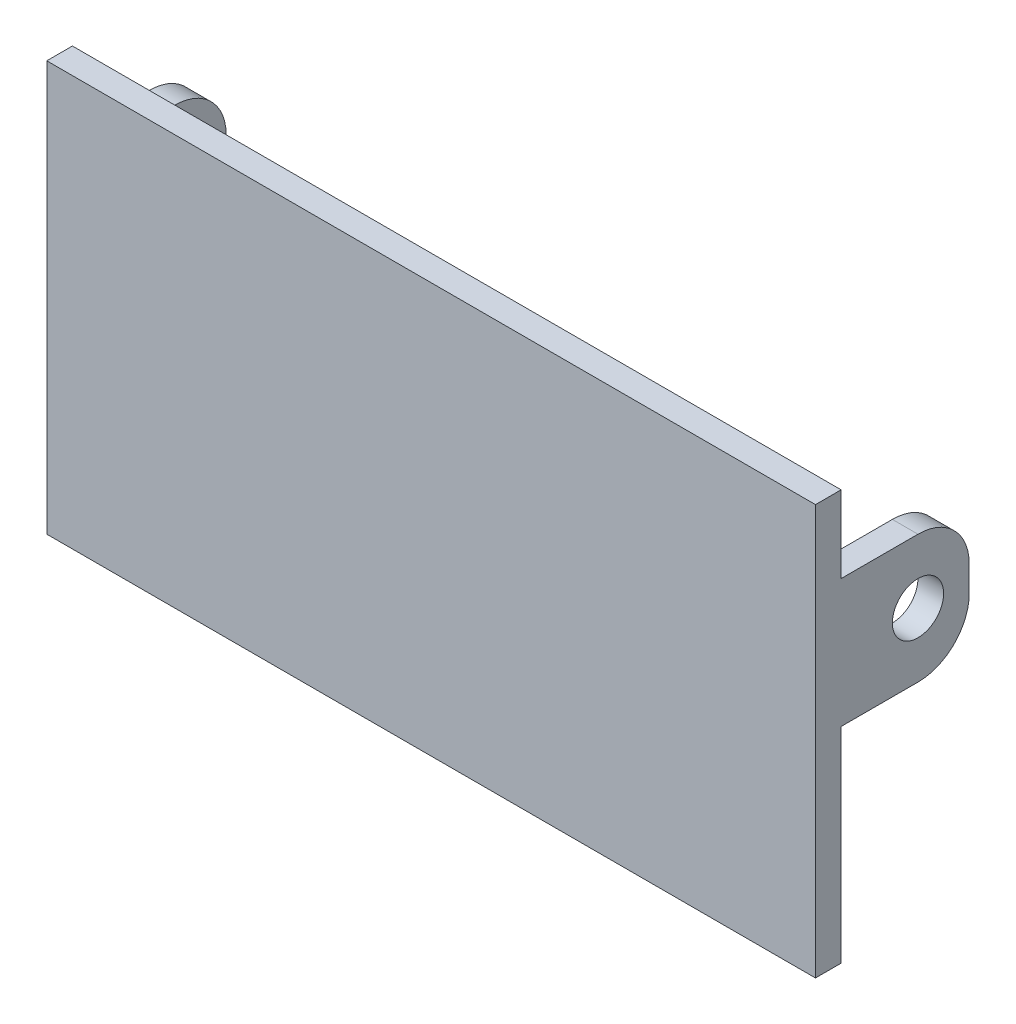
from build123d import *

# Parameters (mm, degrees)
SKETCH1_W           = 150
SKETCH1_H           = 80
BOSS_EXTRUDE1_DEPTH = 5
SKETCH2_W           = 5
SKETCH2_H           = 25
BOSS_EXTRUDE2_DEPTH = 25
SKETCH3_R           = 5
CUT_EXTRUDE1_DEPTH  = 151
FILLET1_R           = 10


with BuildPart() as part:
    # Sketch1 → Boss-Extrude1 (new body)
    with BuildSketch(Plane.XY):
        with Locations((-75, 40)):
            Rectangle(SKETCH1_W, SKETCH1_H)
    extrude(amount=BOSS_EXTRUDE1_DEPTH)

    # Sketch2 → Boss-Extrude2 (add)
    with BuildSketch(Plane(origin=(0, 0, 0), x_dir=(-1, 0, 0), z_dir=(0, 0, -1))):
        with Locations((2.5, 52.5)):
            Rectangle(SKETCH2_W, SKETCH2_H)
        with Locations((147.5, 52.5)):
            Rectangle(SKETCH2_W, SKETCH2_H)
    extrude(amount=BOSS_EXTRUDE2_DEPTH)

    # Sketch3 → Cut-Extrude1 (cut, through all)
    with BuildSketch(Plane(origin=(0, 0, 0), x_dir=(0, 0, -1), z_dir=(1, 0, 0))):
        with Locations(Location((15, 52.5, 0), (0, 0, 90))):  # turned: the seam where the file's is
            Circle(SKETCH3_R)
    extrude(amount=-CUT_EXTRUDE1_DEPTH, mode=Mode.SUBTRACT)

    # Fillet1
    fillet1_edges = [part.edges().sort_by_distance(p)[0] for p in [
        (-2.5, 40, -25),
        (-2.5, 65, -25),
        (-147.5, 65, -25),
        (-147.5, 40, -25),
    ]]
    fillet(fillet1_edges, radius=FILLET1_R)


solid = part.part
